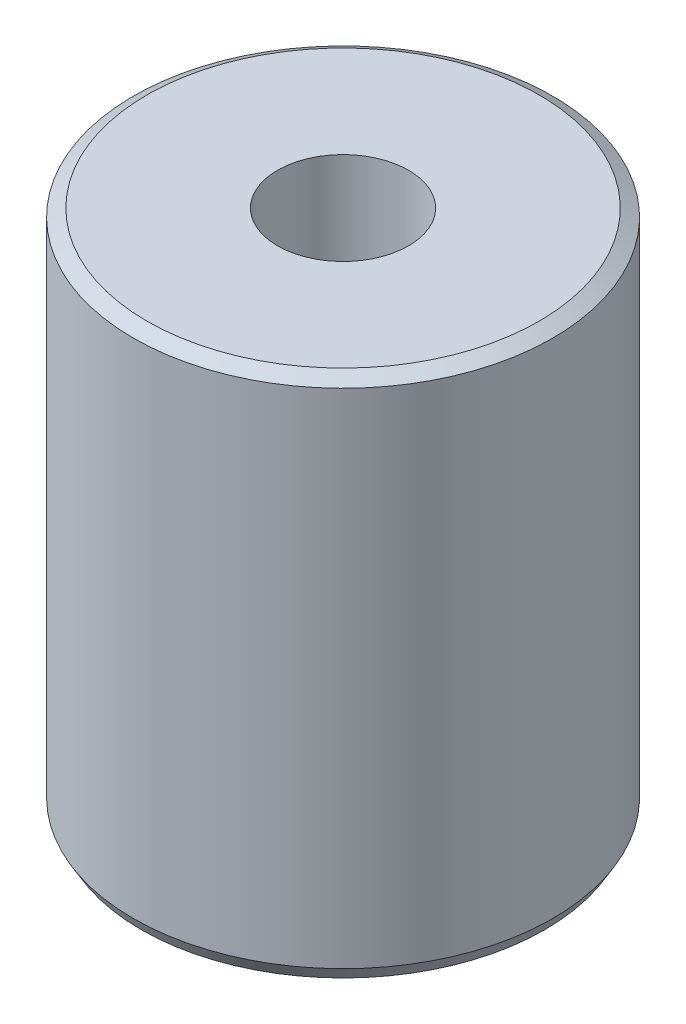
from build123d import *

# Parameters (mm, degrees)
SKETCH1_R             = 4
BOSS_EXTRUDE1_DEPTH   = 10
CHAMFER1_SIZE         = 0.15
CHAMFER1_SIZE2        = 0.259807621
CHAMFER1_PART_2_SIZE  = 0.15
CHAMFER1_PART_2_SIZE2 = 0.259807621
M3X0_5_TAPPED_HOLE1_D = 2.5


with BuildPart() as part:
    # Sketch1 → Boss-Extrude1 (new body)
    with BuildSketch(Plane(origin=(0, 0, 0), x_dir=(1, 0, 0), z_dir=(0, 1, 0))):
        Circle(SKETCH1_R)
    extrude(amount=BOSS_EXTRUDE1_DEPTH)

    # Chamfer1
    chamfer1_edges = [part.edges().sort_by_distance(p)[0] for p in [
        (-4, 0, 0),
    ]]
    chamfer1_side = [part.faces().sort_by_distance(p)[0] for p in [
        (0, 0, 0),
    ]]
    chamfer(chamfer1_edges, length=CHAMFER1_SIZE, length2=CHAMFER1_SIZE2, reference=chamfer1_side[0])

    # Chamfer1 part 2
    chamfer1_part_2_edges = [part.edges().sort_by_distance(p)[0] for p in [
        (-4, 10, 0),
    ]]
    chamfer1_part_2_side = [part.faces().sort_by_distance(p)[0] for p in [
        (-4, 5, 0),
    ]]
    chamfer(chamfer1_part_2_edges, length=CHAMFER1_PART_2_SIZE, length2=CHAMFER1_PART_2_SIZE2, reference=chamfer1_part_2_side[0])

    # M3x0.5 Tapped Hole1 (through all)
    with Locations(Plane(origin=(0, 10, 0), x_dir=(1, 0, 0), z_dir=(0, 1, 0))):
        with Locations((0, 0)):
            Hole(M3X0_5_TAPPED_HOLE1_D / 2)


solid = part.part
